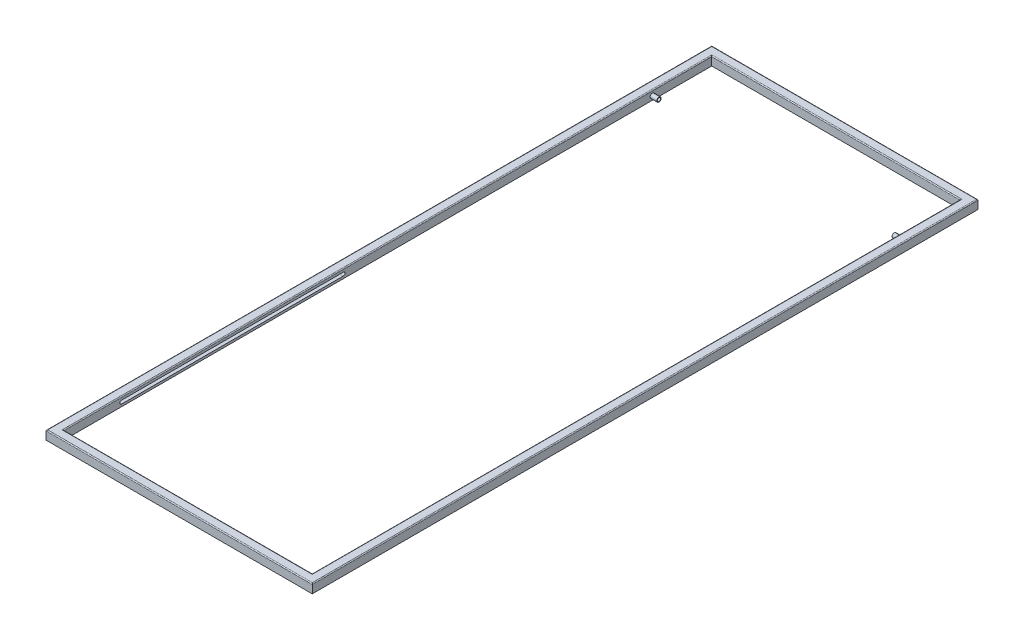
from build123d import *

# Parameters (mm, degrees)
CROQUIS1_W                 = 600
CROQUIS1_H                 = 1500
CROQUIS1_W_2               = 560
CROQUIS1_H_2               = 1460
SALIENTE_EXTRUIR1_DEPTH    = 20
CROQUIS2_R                 = 5
CORTAR_EXTRUIR1_DEPTH      = 15
REDONDEO1_R                = 2
CORTAR_EXTRUIR2_DEPTH      = 575
CORTAR_EXTRUIR2_DEPTH_BACK = 15
CROQUIS5_R                 = 5
CROQUIS5_R_2               = 3.75
SALIENTE_EXTRUIR2_DEPTH    = 15
ESCALA1_SCALE              = 1.3


with BuildPart() as part:
    # Croquis1 → Saliente-Extruir1 (new body)
    with BuildSketch(Plane(origin=(0, 0, 0), x_dir=(1, 0, 0), z_dir=(0, 1, 0))):
        Rectangle(CROQUIS1_W, CROQUIS1_H)
        Rectangle(CROQUIS1_W_2, CROQUIS1_H_2, mode=Mode.SUBTRACT)
    extrude(amount=SALIENTE_EXTRUIR1_DEPTH)

    # Croquis2 → Cortar-Extruir1 (cut)
    with BuildSketch(Plane.XZ):
        with Locations((-290, 740)):
            Circle(CROQUIS2_R)
        with Locations((290, 740)):
            Circle(CROQUIS2_R)
        with Locations((290, -740)):
            Circle(CROQUIS2_R)
        with Locations((-290, -740)):
            Circle(CROQUIS2_R)
    extrude(amount=-CORTAR_EXTRUIR1_DEPTH, mode=Mode.SUBTRACT)

    # Redondeo1
    redondeo1_edges = [part.edges().sort_by_distance(p)[0] for p in [
        (-300, 20, 0),
        (280, 20, 0),
        (0, 20, 750),
        (0, 20, -730),
        (-280, 20, 0),
        (0, 20, 730),
        (300, 20, 0),
        (0, 20, -750),
    ]]
    fillet(redondeo1_edges, radius=REDONDEO1_R)

    # Croquis4 → Cortar-Extruir2 (cut, two sides)
    with BuildSketch(Plane.ZY.offset(-280)) as cortar_extruir2_sk:
        with BuildLine():
            Line((600, 12.75), (100, 12.75))
            Line((100, 12.75), (100, 5.25))
            Line((100, 5.25), (600, 5.25))
            ThreePointArc((600, 5.25), (603.75, 9), (600, 12.75))
        make_face()
        with BuildLine():
            Line((100, 5.25), (100, 12.75))
            ThreePointArc((100, 12.75), (96.25, 9), (100, 5.25))
        make_face()
    extrude(amount=CORTAR_EXTRUIR2_DEPTH, mode=Mode.SUBTRACT)
    extrude(cortar_extruir2_sk.sketch, amount=-CORTAR_EXTRUIR2_DEPTH_BACK, mode=Mode.SUBTRACT)

    # Croquis5 → Saliente-Extruir2 (add)
    with BuildSketch(Plane.ZY.offset(-280)):
        with Locations((-596.25, 9)):
            Circle(CROQUIS5_R)
        with Locations((-596.25, 9)):
            Circle(CROQUIS5_R_2, mode=Mode.SUBTRACT)
    saliente_extruir2 = extrude(amount=SALIENTE_EXTRUIR2_DEPTH)

    # Simetría1: Saliente-Extruir2 across plane
    add(saliente_extruir2.mirror(Plane(origin=(0, 0, 0), x_dir=(0, 0, 1), z_dir=(1, 0, 0))))


with BuildPart() as part_1:
    # Escala1: scaled about (0, 0, 0)
    add(part.part.scale(ESCALA1_SCALE))


solid = part_1.part
